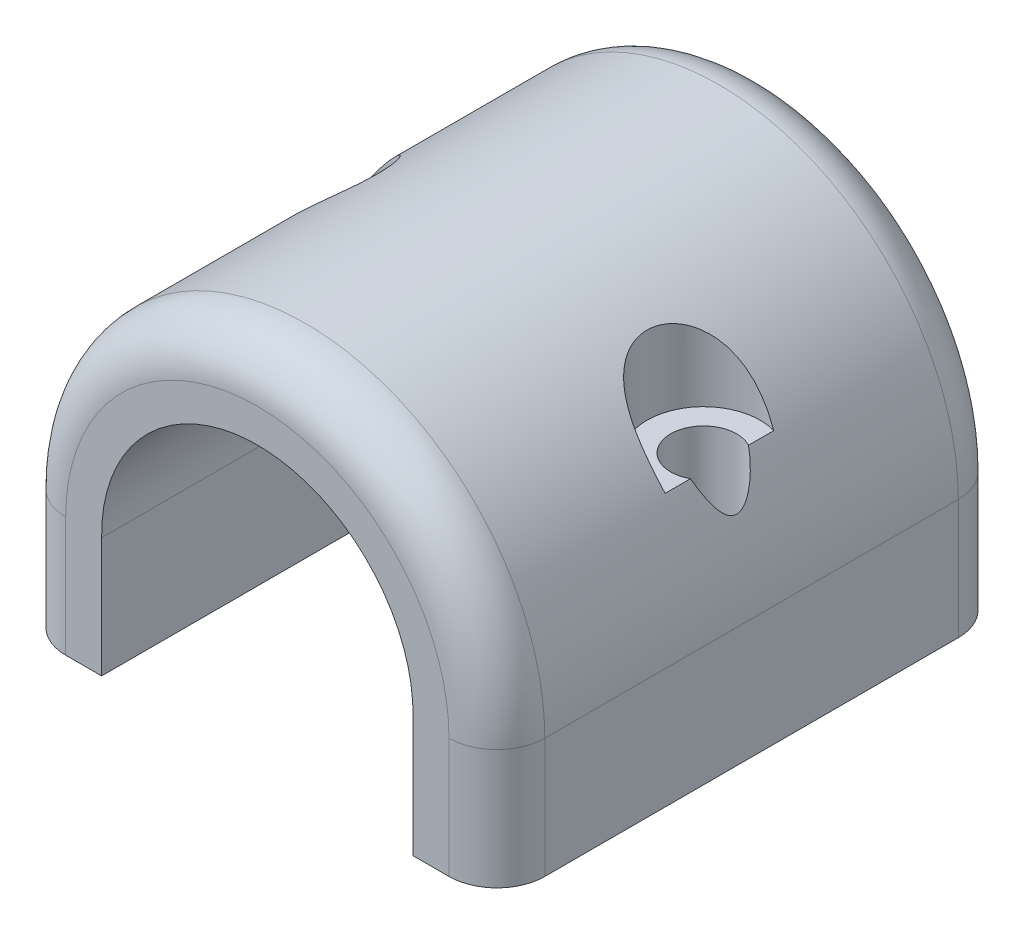
from build123d import *

# Parameters (mm, degrees)
SKETCH1_W           = 25.4
SKETCH1_H           = 27
SKETCH1_R           = 1.75
BOSS_EXTRUDE1_DEPTH = 3.175
SKETCH2_W           = 16.51
SKETCH2_H           = 6.35
CUT_EXTRUDE1_DEPTH  = 28
BOSS_EXTRUDE2_DEPTH = 27
SKETCH4_R           = 1.75
CUT_EXTRUDE2_DEPTH  = 13.7
SKETCH5_R           = 3
CUT_EXTRUDE3_DEPTH  = 6.35
FILLET1_R           = 2.54


with BuildPart() as part:
    # Sketch1 → Boss-Extrude1 (new body, symmetric)
    with BuildSketch(Plane(origin=(0, 0, 0), x_dir=(1, 0, 0), z_dir=(0, 1, 0))):
        Rectangle(SKETCH1_W, SKETCH1_H)
        with Locations((-10.16, 0)):
            Circle(SKETCH1_R, mode=Mode.SUBTRACT)
        with Locations((10.16, 0)):
            Circle(SKETCH1_R, mode=Mode.SUBTRACT)
    extrude(amount=BOSS_EXTRUDE1_DEPTH, both=True)

    # Sketch2 → Cut-Extrude1 (cut, through all)
    with BuildSketch(Plane.XY.offset(13.5)):
        Rectangle(SKETCH2_W, SKETCH2_H)
    extrude(amount=-CUT_EXTRUDE1_DEPTH, mode=Mode.SUBTRACT)

    # Sketch3 → Boss-Extrude2 (add, through all)
    with BuildSketch(Plane.XY.offset(13.5)):
        with BuildLine():
            Line((-12.7, 3.175), (-8.255, 3.175))
            ThreePointArc((-8.255, 3.175), (0, 11.557), (8.255, 3.175))
            Line((8.255, 3.175), (12.7, 3.175))
            ThreePointArc((12.7, 3.175), (0, 15.875), (-12.7, 3.175))
        make_face()
    extrude(amount=-BOSS_EXTRUDE2_DEPTH)

    # Sketch4 → Cut-Extrude2 (cut, through all)
    with BuildSketch(Plane.XZ.offset(-3.175)):
        with Locations((-10.16, 0)):
            Circle(SKETCH4_R)
        with Locations((10.16, 0)):
            Circle(SKETCH4_R)
    extrude(amount=-CUT_EXTRUDE2_DEPTH, mode=Mode.SUBTRACT)

    # Sketch5 → Cut-Extrude3 (cut)
    with BuildSketch(Plane(origin=(0, 15.875, 0), x_dir=(1, 0, 0), z_dir=(0, 1, 0))):
        with Locations((-10.16, 0)):
            Circle(SKETCH5_R)
        with Locations((10.16, 0)):
            Circle(SKETCH5_R)
    extrude(amount=-CUT_EXTRUDE3_DEPTH, mode=Mode.SUBTRACT)

    # Fillet1
    fillet1_edges = [part.edges().sort_by_distance(p)[0] for p in [
        (0, 15.875, -13.5),
        (0, 15.875, 13.5),
        (12.7, 0, -13.5),
        (12.7, 0, 13.5),
        (-12.7, 0, -13.5),
        (-12.7, 0, 13.5),
    ]]
    fillet(fillet1_edges, radius=FILLET1_R)


solid = part.part
